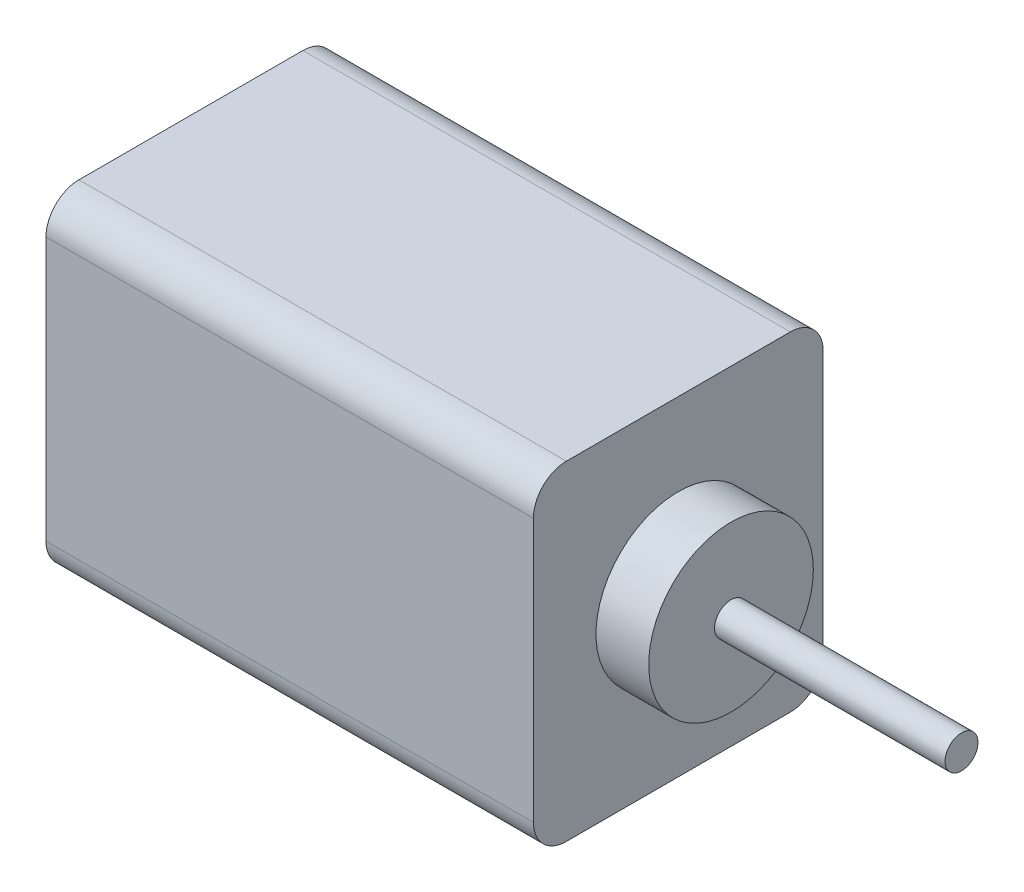
from build123d import *

# Parameters (mm, degrees)
SKETCH1_W           = 74
SKETCH1_H           = 44
BOSS_EXTRUDE1_DEPTH = 50
SKETCH2_R           = 12.5
BOSS_EXTRUDE2_DEPTH = 8
SKETCH3_R           = 2.5
BOSS_EXTRUDE3_DEPTH = 35
FILLET1_R           = 5


with BuildPart() as part:
    # Sketch1 → Boss-Extrude1 (new body)
    with BuildSketch(Plane(origin=(0, 0, 0), x_dir=(1, 0, 0), z_dir=(0, 1, 0))):
        Rectangle(SKETCH1_W, SKETCH1_H)
    extrude(amount=BOSS_EXTRUDE1_DEPTH)

    # Sketch2 → Boss-Extrude2 (add)
    with BuildSketch(Plane(origin=(37, 0, 0), x_dir=(0, 0, -1), z_dir=(1, 0, 0))):
        with Locations((0, 25)):
            Circle(SKETCH2_R)
    extrude(amount=BOSS_EXTRUDE2_DEPTH)

    # Sketch3 → Boss-Extrude3 (add)
    with BuildSketch(Plane(origin=(45, 0, 0), x_dir=(0, 0, -1), z_dir=(1, 0, 0))):
        with Locations((0, 24.783973011)):
            Circle(SKETCH3_R)
    extrude(amount=BOSS_EXTRUDE3_DEPTH)

    # Fillet1
    fillet1_edges = [part.edges().sort_by_distance(p)[0] for p in [
        (0, 50, 22),
        (0, 0, 22),
        (0, 0, -22),
        (0, 50, -22),
    ]]
    fillet(fillet1_edges, radius=FILLET1_R)


solid = part.part
